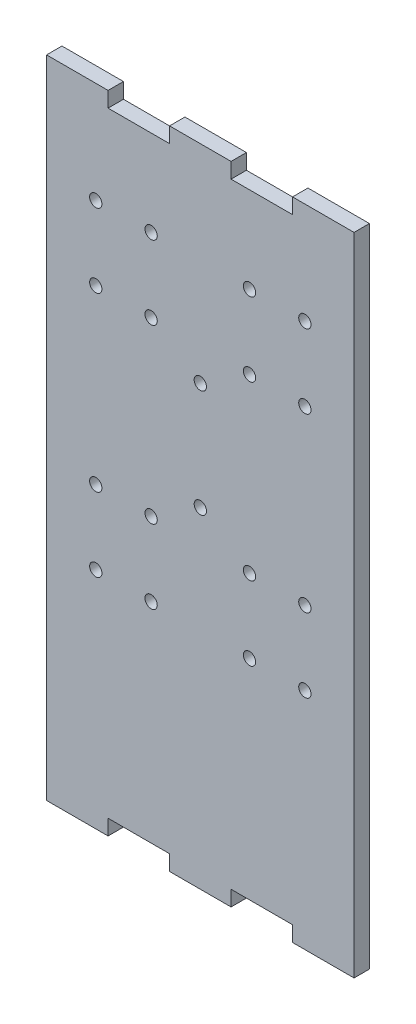
from build123d import *

# Parameters (mm, degrees)
SKETCH1_W           = 100
SKETCH1_H           = 210
BOSS_EXTRUDE1_DEPTH = 5
SKETCH4_W           = 20
SKETCH4_H           = 5
CUT_EXTRUDE3_DEPTH  = 10
SKETCH5_R           = 2
CUT_EXTRUDE4_DEPTH  = 6
SKETCH7_R           = 2
CUT_EXTRUDE5_DEPTH  = 10


with BuildPart() as part:
    # Sketch1 → Boss-Extrude1 (new body)
    with BuildSketch(Plane.XY):
        with Locations((0, -20)):
            Rectangle(SKETCH1_W, SKETCH1_H)
    extrude(amount=BOSS_EXTRUDE1_DEPTH)

    # Sketch4 → Cut-Extrude3 (cut)
    with BuildSketch(Plane.XY.offset(5)):
        with Locations((-20, 82.5)):
            Rectangle(SKETCH4_W, SKETCH4_H)
        with Locations((20, 82.5)):
            Rectangle(SKETCH4_W, SKETCH4_H)
        with Locations((20, -122.5)):
            Rectangle(SKETCH4_W, SKETCH4_H)
        with Locations((-20, -122.5)):
            Rectangle(SKETCH4_W, SKETCH4_H)
    extrude(amount=-CUT_EXTRUDE3_DEPTH, mode=Mode.SUBTRACT)

    # Sketch5 → Cut-Extrude4 (cut, through all)
    with BuildSketch(Plane.XY.offset(5)):
        with Locations((34, 52)):
            Circle(SKETCH5_R)
        with Locations((16, 52)):
            Circle(SKETCH5_R)
        with Locations((16, 28)):
            Circle(SKETCH5_R)
        with Locations((34, 28)):
            Circle(SKETCH5_R)
        with Locations((-16, 28)):
            Circle(SKETCH5_R)
        with Locations((-34, 28)):
            Circle(SKETCH5_R)
        with Locations((-34, 52)):
            Circle(SKETCH5_R)
        with Locations((-16, 52)):
            Circle(SKETCH5_R)
        with Locations((-16, -52)):
            Circle(SKETCH5_R)
        with Locations((-34, -52)):
            Circle(SKETCH5_R)
        with Locations((-34, -28)):
            Circle(SKETCH5_R)
        with Locations((-16, -28)):
            Circle(SKETCH5_R)
        with Locations((16, -28)):
            Circle(SKETCH5_R)
        with Locations((34, -28)):
            Circle(SKETCH5_R)
        with Locations((34, -52)):
            Circle(SKETCH5_R)
        with Locations((16, -52)):
            Circle(SKETCH5_R)
    extrude(amount=-CUT_EXTRUDE4_DEPTH, mode=Mode.SUBTRACT)

    # Sketch7 → Cut-Extrude5 (cut)
    with BuildSketch(Plane.XY.offset(5)):
        with Locations((0, 17.5)):
            Circle(SKETCH7_R)
        with Locations((0, -17.5)):
            Circle(SKETCH7_R)
    extrude(amount=-CUT_EXTRUDE5_DEPTH, mode=Mode.SUBTRACT)


solid = part.part
